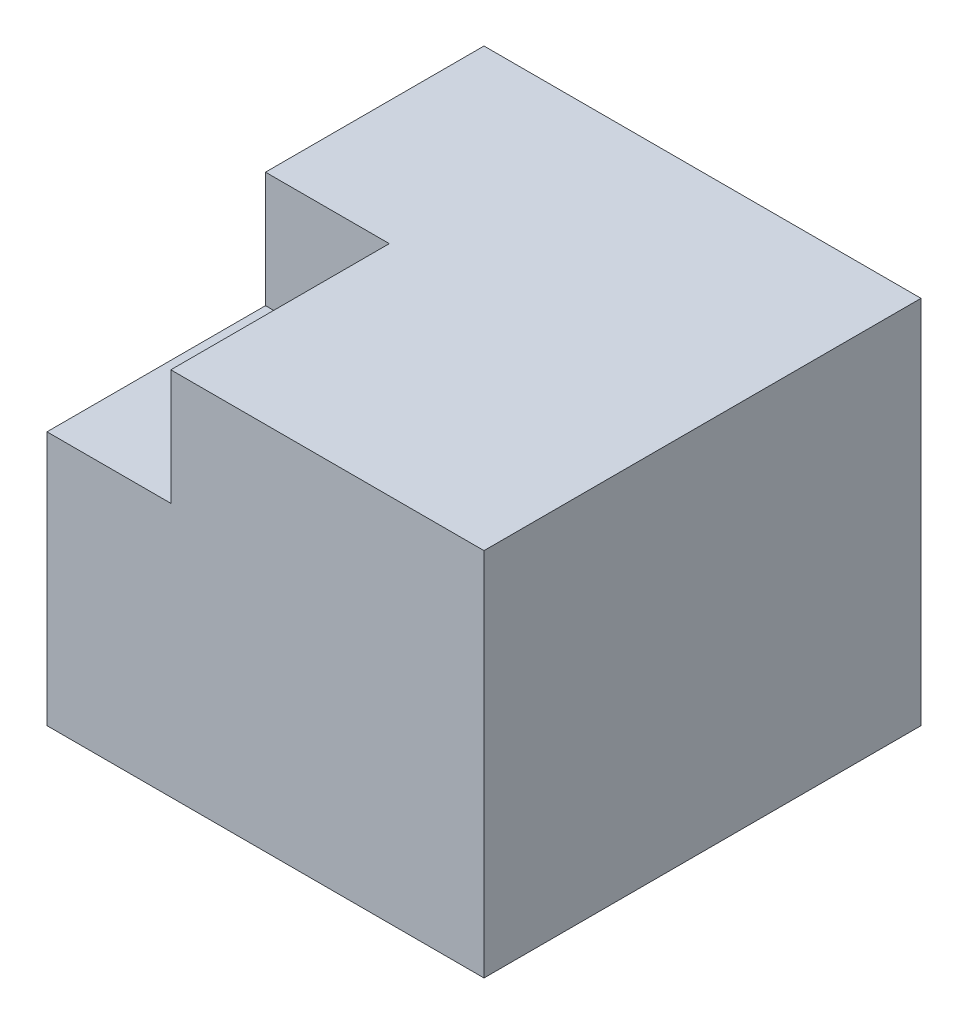
from build123d import *

# Parameters (mm, degrees)
SKETCH1_W           = 10
SKETCH1_H           = 8.469387756
BOSS_EXTRUDE1_DEPTH = 10
SKETCH2_W           = 2.833290323
SKETCH2_H           = 2.645406831
CUT_EXTRUDE1_DEPTH  = 5


with BuildPart() as part:
    # Sketch1 → Boss-Extrude1 (new body)
    with BuildSketch(Plane.XY):
        Rectangle(SKETCH1_W, SKETCH1_H)
    extrude(amount=BOSS_EXTRUDE1_DEPTH)

    # Sketch2 → Cut-Extrude1 (cut)
    with BuildSketch(Plane.XY.offset(10)):
        with Locations((-3.583354839, 2.911990462)):
            Rectangle(SKETCH2_W, SKETCH2_H)
    extrude(amount=-CUT_EXTRUDE1_DEPTH, mode=Mode.SUBTRACT)


solid = part.part
